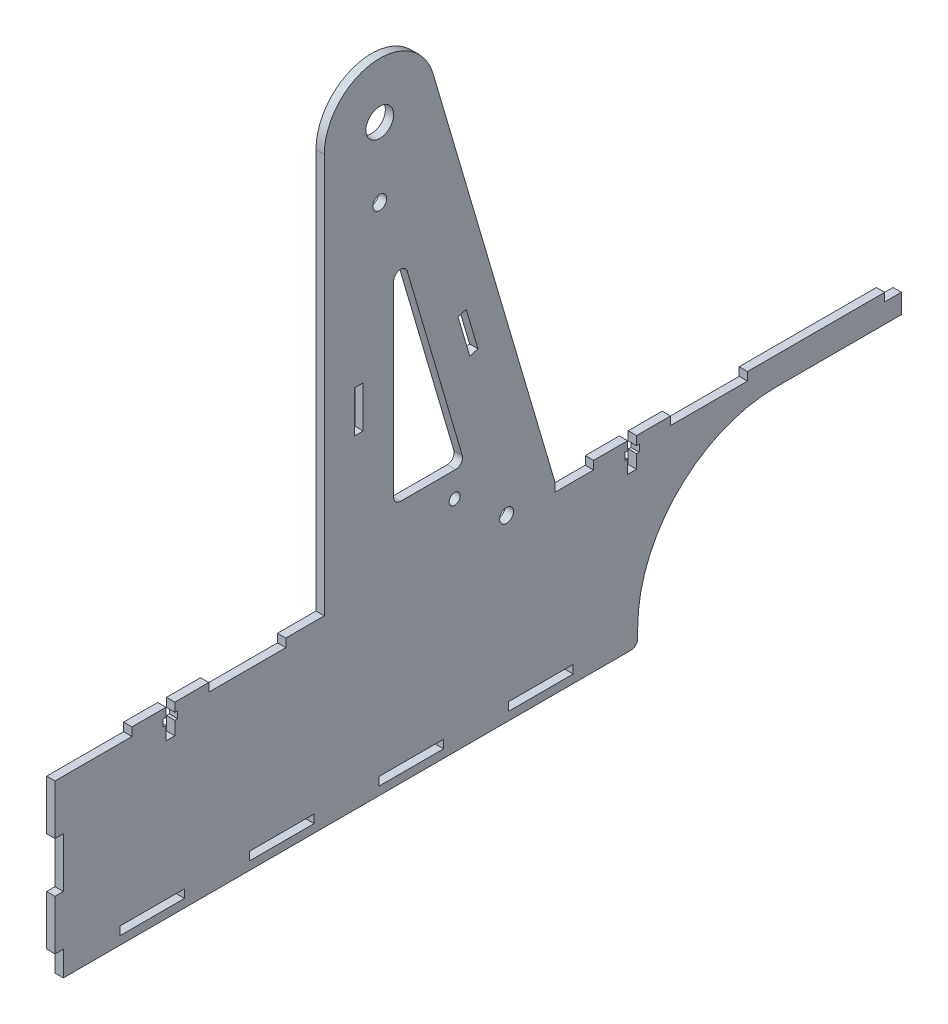
from build123d import *

# Parameters (mm, degrees)
BOSS_EXTRUDE1_DEPTH     = 3
SKETCH2_W               = 27.727272727
SKETCH2_H               = 3
SKETCH2_W_2             = 3
SKETCH2_H_2             = 18
SKETCH2_H_3             = 9
SKETCH2_W_3             = 23.343342349
SKETCH2_W_4             = 23.34334235
SKETCH2_W_5             = 6
CUT_EXTRUDE1_DEPTH      = 1
CUT_EXTRUDE1_DEPTH_BACK = 4
SKETCH3_W               = 3.2
SKETCH3_H               = 10.5
SKETCH3_W_2             = 5.2
SKETCH3_H_2             = 2.5
CUT_EXTRUDE2_DEPTH      = 1
CUT_EXTRUDE2_DEPTH_BACK = 4
FILLET1_R               = 2.5
SKETCH4_R               = 5
BOSS_EXTRUDE2_DEPTH     = 3
FILLET2_R               = 2.5
SKETCH5_R               = 2.5
SKETCH5_R_2             = 2
SKETCH5_W               = 3.05
SKETCH5_H               = 15
CUT_EXTRUDE3_DEPTH      = 1
CUT_EXTRUDE3_DEPTH_BACK = 4


with BuildPart() as part:
    # Sketch1 → Boss-Extrude1 (new body)
    with BuildSketch(Plane(origin=(0, 0, 0), x_dir=(0, 0, -1), z_dir=(1, 0, 0))):
        with BuildLine():
            Line((-152.5, 33), (152.5, 33))
            Line((152.5, 33), (152.5, 23))
            Line((152.5, 23), (107.5, 23))
            ThreePointArc((107.5, 23), (72.144660941, 8.355339059), (57.5, -27))
            Line((57.5, -27), (57.5, -33))
            Line((57.5, -33), (-152.5, -33))
            Line((-152.5, -33), (-152.5, 33))
        make_face()
    extrude(amount=BOSS_EXTRUDE1_DEPTH)

    # Sketch2 → Cut-Extrude1 (cut, two sides)
    with BuildSketch(Plane(origin=(3, 0, 0), x_dir=(0, 0, -1), z_dir=(1, 0, 0))) as cut_extrude1_sk:
        with Locations((27.727272728, 31.5)):
            Rectangle(SKETCH2_W, SKETCH2_H)
        with Locations((83.181818182, 31.5)):
            Rectangle(SKETCH2_W, SKETCH2_H)
        with Locations((-138.636363636, 31.5)):
            Rectangle(SKETCH2_W, SKETCH2_H)
        with Locations((-83.181818182, 31.5)):
            Rectangle(SKETCH2_W, SKETCH2_H)
        with Locations((-27.727272728, 31.5)):
            Rectangle(SKETCH2_W, SKETCH2_H)
        with Locations((-151, 3)):
            Rectangle(SKETCH2_W_2, SKETCH2_H_2)
        with Locations((-151, -28.5)):
            Rectangle(SKETCH2_W_2, SKETCH2_H_3)
        with Locations((-117.484986475, -28.5)):
            Rectangle(SKETCH2_W_3, SKETCH2_H)
        with Locations((-70.798301777, -28.5)):
            Rectangle(SKETCH2_W_3, SKETCH2_H)
        with Locations((22.575067622, -28.5)):
            Rectangle(SKETCH2_W_4, SKETCH2_H)
        with Locations((149.5, 31.5)):
            Rectangle(SKETCH2_W_5, SKETCH2_H)
        with Locations((-24.111617078, -28.5)):
            Rectangle(SKETCH2_W_3, SKETCH2_H)
    extrude(amount=CUT_EXTRUDE1_DEPTH, mode=Mode.SUBTRACT)
    extrude(cut_extrude1_sk.sketch, amount=-CUT_EXTRUDE1_DEPTH_BACK, mode=Mode.SUBTRACT)

    # Sketch3 → Cut-Extrude2 (cut, two sides)
    with BuildSketch(Plane(origin=(3, 0, 0), x_dir=(0, 0, -1), z_dir=(1, 0, 0))) as cut_extrude2_sk:
        with Locations((-110.909090909, 27.75)):
            Rectangle(SKETCH3_W, SKETCH3_H)
        with Locations((55.454545455, 27.75)):
            Rectangle(SKETCH3_W, SKETCH3_H)
        with Locations((55.454545455, 28.575)):
            Rectangle(SKETCH3_W_2, SKETCH3_H_2)
        with Locations((-110.909090909, 28.575)):
            Rectangle(SKETCH3_W_2, SKETCH3_H_2)
    extrude(amount=CUT_EXTRUDE2_DEPTH, mode=Mode.SUBTRACT)
    extrude(cut_extrude2_sk.sketch, amount=-CUT_EXTRUDE2_DEPTH_BACK, mode=Mode.SUBTRACT)

    # Fillet1
    fillet1_edges = [part.edges().sort_by_distance(p)[0] for p in [
        (1.5, -33, -57.5),
    ]]
    fillet(fillet1_edges, radius=FILLET1_R)

    # Sketch4 → Boss-Extrude2 (add)
    with BuildSketch(Plane(origin=(0, 0, 0), x_dir=(0, 0, -1), z_dir=(1, 0, 0))):
        with BuildLine():
            Line((-55.454545455, 30), (-55.454545455, 177))
            ThreePointArc((-55.454545455, 177), (-38.304207087, 196.795944751), (-16.266602596, 182.641174423))
            Line((-16.266602596, 182.641174423), (27.727272727, 33))
            Line((27.727272727, 33), (27.727272727, 30))
            Line((27.727272727, 30), (-55.454545455, 30))
        make_face()
        with Locations((-35.454545455, 177)):
            Circle(SKETCH4_R, mode=Mode.SUBTRACT)
        Polygon((-30.454545455, 55), (-4.798665146, 55), (-30.454545455, 142.266148573), align=None, mode=Mode.SUBTRACT)
    extrude(amount=BOSS_EXTRUDE2_DEPTH)

    # Fillet2
    fillet2_edges = [part.edges().sort_by_distance(p)[0] for p in [
        (1.5, 55, 30.454545455),
        (1.5, 55, 4.798665146),
        (1.5, 142.266148573, 30.454545455),
    ]]
    fillet(fillet2_edges, radius=FILLET2_R)

    # Sketch5 → Cut-Extrude3 (cut, two sides)
    with BuildSketch(Plane(origin=(3, 0, 0), x_dir=(0, 0, -1), z_dir=(1, 0, 0))) as cut_extrude3_sk:
        with Locations((10.227172727, 31.5)):
            Circle(SKETCH5_R)
        with Locations((-35.454545455, 152)):
            Circle(SKETCH5_R)
        with Locations((-8.454545455, 46)):
            Circle(SKETCH5_R_2)
        Polygon((-3.003684653, 87.804874126), (-7.23456547, 102.195831269), (-4.308404184, 103.056110369), (-0.077523367, 88.665153225), align=None)
        with Locations((-42.954545455, 91.19961143)):
            Rectangle(SKETCH5_W, SKETCH5_H)
    extrude(amount=CUT_EXTRUDE3_DEPTH, mode=Mode.SUBTRACT)
    extrude(cut_extrude3_sk.sketch, amount=-CUT_EXTRUDE3_DEPTH_BACK, mode=Mode.SUBTRACT)


solid = part.part
